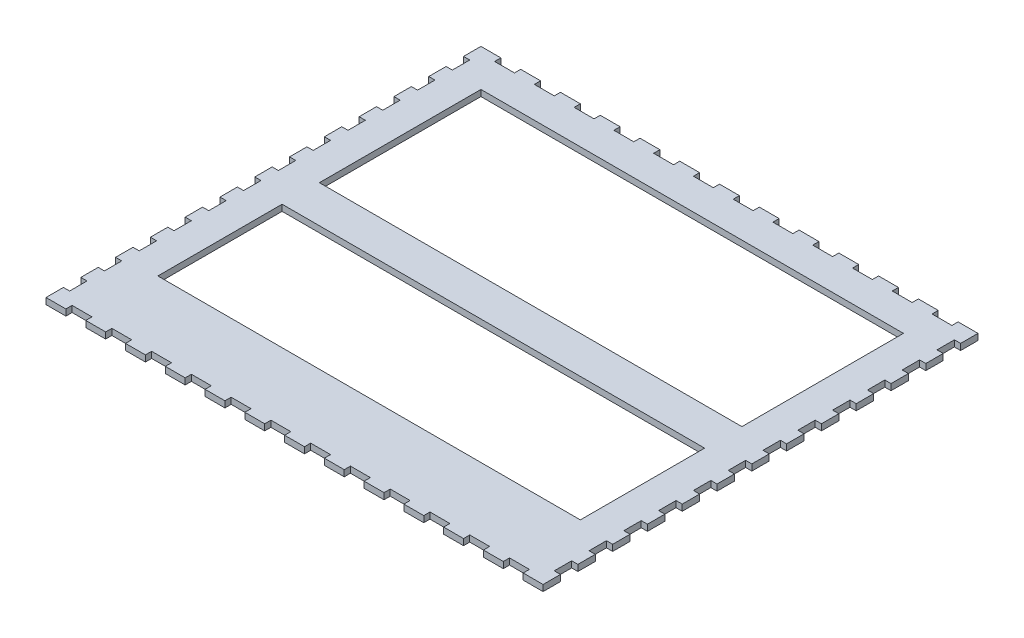
from build123d import *

# Parameters (mm, degrees)
ESQUISSE1_W                = 400
ESQUISSE1_H                = 350
BOSS_EXTRU_1_DEPTH         = 5
ESQUISSE2_W                = 16
ESQUISSE2_H                = 5
ENL_V_MAT_EXTRU_1_DEPTH    = 5
R_P_TITION_LIN_AIRE1_COUNT = 12
R_P_TITION_LIN_AIRE1_PITCH = 32
ESQUISSE3_W                = 5
ESQUISSE3_H                = 14
ENL_V_MAT_EXTRU_2_DEPTH    = 5
R_P_TITION_LIN_AIRE2_COUNT = 12
R_P_TITION_LIN_AIRE2_PITCH = 28
SYM_TRIE1_COPY_1_SKETCH_W  = 16
SYM_TRIE1_COPY_1_SKETCH_H  = 5
SYM_TRIE1_COPY_1_DEPTH     = 5
SYM_TRIE1_COPY_2_SKETCH_W  = 16
SYM_TRIE1_COPY_2_SKETCH_H  = 5
SYM_TRIE1_COPY_2_DEPTH     = 5
SYM_TRIE1_COPY_3_SKETCH_W  = 16
SYM_TRIE1_COPY_3_SKETCH_H  = 5
SYM_TRIE1_COPY_3_DEPTH     = 5
SYM_TRIE1_COPY_4_SKETCH_W  = 16
SYM_TRIE1_COPY_4_SKETCH_H  = 5
SYM_TRIE1_COPY_4_DEPTH     = 5
SYM_TRIE1_COPY_5_SKETCH_W  = 16
SYM_TRIE1_COPY_5_SKETCH_H  = 5
SYM_TRIE1_COPY_5_DEPTH     = 5
SYM_TRIE1_COPY_6_SKETCH_W  = 16
SYM_TRIE1_COPY_6_SKETCH_H  = 5
SYM_TRIE1_COPY_6_DEPTH     = 5
SYM_TRIE1_COPY_7_SKETCH_W  = 16
SYM_TRIE1_COPY_7_SKETCH_H  = 5
SYM_TRIE1_COPY_7_DEPTH     = 5
SYM_TRIE1_COPY_8_SKETCH_W  = 16
SYM_TRIE1_COPY_8_SKETCH_H  = 5
SYM_TRIE1_COPY_8_DEPTH     = 5
SYM_TRIE1_COPY_9_SKETCH_W  = 16
SYM_TRIE1_COPY_9_SKETCH_H  = 5
SYM_TRIE1_COPY_9_DEPTH     = 5
SYM_TRIE1_COPY_10_SKETCH_W = 16
SYM_TRIE1_COPY_10_SKETCH_H = 5
SYM_TRIE1_COPY_10_DEPTH    = 5
SYM_TRIE1_COPY_11_SKETCH_W = 16
SYM_TRIE1_COPY_11_SKETCH_H = 5
SYM_TRIE1_COPY_11_DEPTH    = 5
SYM_TRIE2_COPY_1_SKETCH_W  = 5
SYM_TRIE2_COPY_1_SKETCH_H  = 14
SYM_TRIE2_COPY_1_DEPTH     = 5
SYM_TRIE2_COPY_2_SKETCH_W  = 5
SYM_TRIE2_COPY_2_SKETCH_H  = 14
SYM_TRIE2_COPY_2_DEPTH     = 5
SYM_TRIE2_COPY_3_SKETCH_W  = 5
SYM_TRIE2_COPY_3_SKETCH_H  = 14
SYM_TRIE2_COPY_3_DEPTH     = 5
SYM_TRIE2_COPY_4_SKETCH_W  = 5
SYM_TRIE2_COPY_4_SKETCH_H  = 14
SYM_TRIE2_COPY_4_DEPTH     = 5
SYM_TRIE2_COPY_5_SKETCH_W  = 5
SYM_TRIE2_COPY_5_SKETCH_H  = 14
SYM_TRIE2_COPY_5_DEPTH     = 5
SYM_TRIE2_COPY_6_SKETCH_W  = 5
SYM_TRIE2_COPY_6_SKETCH_H  = 14
SYM_TRIE2_COPY_6_DEPTH     = 5
SYM_TRIE2_COPY_7_SKETCH_W  = 5
SYM_TRIE2_COPY_7_SKETCH_H  = 14
SYM_TRIE2_COPY_7_DEPTH     = 5
SYM_TRIE2_COPY_8_SKETCH_W  = 5
SYM_TRIE2_COPY_8_SKETCH_H  = 14
SYM_TRIE2_COPY_8_DEPTH     = 5
SYM_TRIE2_COPY_9_SKETCH_W  = 5
SYM_TRIE2_COPY_9_SKETCH_H  = 14
SYM_TRIE2_COPY_9_DEPTH     = 5
SYM_TRIE2_COPY_10_SKETCH_W = 5
SYM_TRIE2_COPY_10_SKETCH_H = 14
SYM_TRIE2_COPY_10_DEPTH    = 5
SYM_TRIE2_COPY_11_SKETCH_W = 5
SYM_TRIE2_COPY_11_SKETCH_H = 14
SYM_TRIE2_COPY_11_DEPTH    = 5
ESQUISSE4_W                = 340
ESQUISSE4_H                = 130
ENL_V_MAT_EXTRU_3_DEPTH    = 10
ESQUISSE5_W                = 340
ESQUISSE5_H                = 100
ENL_V_MAT_EXTRU_4_DEPTH    = 10


with BuildPart() as part:
    # Esquisse1 → Boss.-Extru.1 (new body)
    with BuildSketch(Plane(origin=(0, 0, 0), x_dir=(1, 0, 0), z_dir=(0, 1, 0))):
        with Locations((200, -175)):
            Rectangle(ESQUISSE1_W, ESQUISSE1_H)
    extrude(amount=BOSS_EXTRU_1_DEPTH)

    # Esquisse2 → Enlèv. mat.-Extru.1 (cut)
    with BuildSketch(Plane(origin=(0, 5, 0), x_dir=(1, 0, 0), z_dir=(0, 1, 0))):
        with Locations((24, -2.5)):
            Rectangle(ESQUISSE2_W, ESQUISSE2_H)
    enl_v_mat_extru_1 = extrude(amount=-ENL_V_MAT_EXTRU_1_DEPTH, mode=Mode.SUBTRACT)

    # Répétition linéaire1: Enlèv. mat.-Extru.1 ×12
    with Locations(*[(i * R_P_TITION_LIN_AIRE1_PITCH, 0, 0) for i in range(1, R_P_TITION_LIN_AIRE1_COUNT)]):
        add(enl_v_mat_extru_1, mode=Mode.SUBTRACT)

    # Esquisse3 → Enlèv. mat.-Extru.2 (cut)
    with BuildSketch(Plane(origin=(0, 5, 0), x_dir=(1, 0, 0), z_dir=(0, 1, 0))):
        with Locations((2.5, -21)):
            Rectangle(ESQUISSE3_W, ESQUISSE3_H)
    enl_v_mat_extru_2 = extrude(amount=-ENL_V_MAT_EXTRU_2_DEPTH, mode=Mode.SUBTRACT)

    # Répétition linéaire2: Enlèv. mat.-Extru.2 ×12
    with Locations(*[(0, 0, i * R_P_TITION_LIN_AIRE2_PITCH) for i in range(1, R_P_TITION_LIN_AIRE2_COUNT)]):
        add(enl_v_mat_extru_2, mode=Mode.SUBTRACT)

    # Symétrie1: Enlèv. mat.-Extru.1 across plane
    add(enl_v_mat_extru_1.mirror(Plane(origin=(0, 0, 175), x_dir=(1, 0, 0), z_dir=(0, 0, -1))), mode=Mode.SUBTRACT)

    # Symétrie1 copy 1 sketch → Symétrie1 copy 1 (cut)
    with BuildSketch(Plane(origin=(32, 5, 350), x_dir=(1, 0, 0), z_dir=(0, 1, 0))):
        with Locations((24, 2.5)):
            Rectangle(SYM_TRIE1_COPY_1_SKETCH_W, SYM_TRIE1_COPY_1_SKETCH_H)
    extrude(amount=-SYM_TRIE1_COPY_1_DEPTH, mode=Mode.SUBTRACT)

    # Symétrie1 copy 2 sketch → Symétrie1 copy 2 (cut)
    with BuildSketch(Plane(origin=(64, 5, 350), x_dir=(1, 0, 0), z_dir=(0, 1, 0))):
        with Locations((24, 2.5)):
            Rectangle(SYM_TRIE1_COPY_2_SKETCH_W, SYM_TRIE1_COPY_2_SKETCH_H)
    extrude(amount=-SYM_TRIE1_COPY_2_DEPTH, mode=Mode.SUBTRACT)

    # Symétrie1 copy 3 sketch → Symétrie1 copy 3 (cut)
    with BuildSketch(Plane(origin=(96, 5, 350), x_dir=(1, 0, 0), z_dir=(0, 1, 0))):
        with Locations((24, 2.5)):
            Rectangle(SYM_TRIE1_COPY_3_SKETCH_W, SYM_TRIE1_COPY_3_SKETCH_H)
    extrude(amount=-SYM_TRIE1_COPY_3_DEPTH, mode=Mode.SUBTRACT)

    # Symétrie1 copy 4 sketch → Symétrie1 copy 4 (cut)
    with BuildSketch(Plane(origin=(128, 5, 350), x_dir=(1, 0, 0), z_dir=(0, 1, 0))):
        with Locations((24, 2.5)):
            Rectangle(SYM_TRIE1_COPY_4_SKETCH_W, SYM_TRIE1_COPY_4_SKETCH_H)
    extrude(amount=-SYM_TRIE1_COPY_4_DEPTH, mode=Mode.SUBTRACT)

    # Symétrie1 copy 5 sketch → Symétrie1 copy 5 (cut)
    with BuildSketch(Plane(origin=(160, 5, 350), x_dir=(1, 0, 0), z_dir=(0, 1, 0))):
        with Locations((24, 2.5)):
            Rectangle(SYM_TRIE1_COPY_5_SKETCH_W, SYM_TRIE1_COPY_5_SKETCH_H)
    extrude(amount=-SYM_TRIE1_COPY_5_DEPTH, mode=Mode.SUBTRACT)

    # Symétrie1 copy 6 sketch → Symétrie1 copy 6 (cut)
    with BuildSketch(Plane(origin=(192, 5, 350), x_dir=(1, 0, 0), z_dir=(0, 1, 0))):
        with Locations((24, 2.5)):
            Rectangle(SYM_TRIE1_COPY_6_SKETCH_W, SYM_TRIE1_COPY_6_SKETCH_H)
    extrude(amount=-SYM_TRIE1_COPY_6_DEPTH, mode=Mode.SUBTRACT)

    # Symétrie1 copy 7 sketch → Symétrie1 copy 7 (cut)
    with BuildSketch(Plane(origin=(224, 5, 350), x_dir=(1, 0, 0), z_dir=(0, 1, 0))):
        with Locations((24, 2.5)):
            Rectangle(SYM_TRIE1_COPY_7_SKETCH_W, SYM_TRIE1_COPY_7_SKETCH_H)
    extrude(amount=-SYM_TRIE1_COPY_7_DEPTH, mode=Mode.SUBTRACT)

    # Symétrie1 copy 8 sketch → Symétrie1 copy 8 (cut)
    with BuildSketch(Plane(origin=(256, 5, 350), x_dir=(1, 0, 0), z_dir=(0, 1, 0))):
        with Locations((24, 2.5)):
            Rectangle(SYM_TRIE1_COPY_8_SKETCH_W, SYM_TRIE1_COPY_8_SKETCH_H)
    extrude(amount=-SYM_TRIE1_COPY_8_DEPTH, mode=Mode.SUBTRACT)

    # Symétrie1 copy 9 sketch → Symétrie1 copy 9 (cut)
    with BuildSketch(Plane(origin=(288, 5, 350), x_dir=(1, 0, 0), z_dir=(0, 1, 0))):
        with Locations((24, 2.5)):
            Rectangle(SYM_TRIE1_COPY_9_SKETCH_W, SYM_TRIE1_COPY_9_SKETCH_H)
    extrude(amount=-SYM_TRIE1_COPY_9_DEPTH, mode=Mode.SUBTRACT)

    # Symétrie1 copy 10 sketch → Symétrie1 copy 10 (cut)
    with BuildSketch(Plane(origin=(320, 5, 350), x_dir=(1, 0, 0), z_dir=(0, 1, 0))):
        with Locations((24, 2.5)):
            Rectangle(SYM_TRIE1_COPY_10_SKETCH_W, SYM_TRIE1_COPY_10_SKETCH_H)
    extrude(amount=-SYM_TRIE1_COPY_10_DEPTH, mode=Mode.SUBTRACT)

    # Symétrie1 copy 11 sketch → Symétrie1 copy 11 (cut)
    with BuildSketch(Plane(origin=(352, 5, 350), x_dir=(1, 0, 0), z_dir=(0, 1, 0))):
        with Locations((24, 2.5)):
            Rectangle(SYM_TRIE1_COPY_11_SKETCH_W, SYM_TRIE1_COPY_11_SKETCH_H)
    extrude(amount=-SYM_TRIE1_COPY_11_DEPTH, mode=Mode.SUBTRACT)

    # Symétrie2: Enlèv. mat.-Extru.2 across plane
    add(enl_v_mat_extru_2.mirror(Plane(origin=(200, 0, 0), x_dir=(0, 0, 1), z_dir=(1, 0, 0))), mode=Mode.SUBTRACT)

    # Symétrie2 copy 1 sketch → Symétrie2 copy 1 (cut)
    with BuildSketch(Plane(origin=(400, 5, 28), x_dir=(-1, 0, 0), z_dir=(0, 1, 0))):
        with Locations((2.5, 21)):
            Rectangle(SYM_TRIE2_COPY_1_SKETCH_W, SYM_TRIE2_COPY_1_SKETCH_H)
    extrude(amount=-SYM_TRIE2_COPY_1_DEPTH, mode=Mode.SUBTRACT)

    # Symétrie2 copy 2 sketch → Symétrie2 copy 2 (cut)
    with BuildSketch(Plane(origin=(400, 5, 56), x_dir=(-1, 0, 0), z_dir=(0, 1, 0))):
        with Locations((2.5, 21)):
            Rectangle(SYM_TRIE2_COPY_2_SKETCH_W, SYM_TRIE2_COPY_2_SKETCH_H)
    extrude(amount=-SYM_TRIE2_COPY_2_DEPTH, mode=Mode.SUBTRACT)

    # Symétrie2 copy 3 sketch → Symétrie2 copy 3 (cut)
    with BuildSketch(Plane(origin=(400, 5, 84), x_dir=(-1, 0, 0), z_dir=(0, 1, 0))):
        with Locations((2.5, 21)):
            Rectangle(SYM_TRIE2_COPY_3_SKETCH_W, SYM_TRIE2_COPY_3_SKETCH_H)
    extrude(amount=-SYM_TRIE2_COPY_3_DEPTH, mode=Mode.SUBTRACT)

    # Symétrie2 copy 4 sketch → Symétrie2 copy 4 (cut)
    with BuildSketch(Plane(origin=(400, 5, 112), x_dir=(-1, 0, 0), z_dir=(0, 1, 0))):
        with Locations((2.5, 21)):
            Rectangle(SYM_TRIE2_COPY_4_SKETCH_W, SYM_TRIE2_COPY_4_SKETCH_H)
    extrude(amount=-SYM_TRIE2_COPY_4_DEPTH, mode=Mode.SUBTRACT)

    # Symétrie2 copy 5 sketch → Symétrie2 copy 5 (cut)
    with BuildSketch(Plane(origin=(400, 5, 140), x_dir=(-1, 0, 0), z_dir=(0, 1, 0))):
        with Locations((2.5, 21)):
            Rectangle(SYM_TRIE2_COPY_5_SKETCH_W, SYM_TRIE2_COPY_5_SKETCH_H)
    extrude(amount=-SYM_TRIE2_COPY_5_DEPTH, mode=Mode.SUBTRACT)

    # Symétrie2 copy 6 sketch → Symétrie2 copy 6 (cut)
    with BuildSketch(Plane(origin=(400, 5, 168), x_dir=(-1, 0, 0), z_dir=(0, 1, 0))):
        with Locations((2.5, 21)):
            Rectangle(SYM_TRIE2_COPY_6_SKETCH_W, SYM_TRIE2_COPY_6_SKETCH_H)
    extrude(amount=-SYM_TRIE2_COPY_6_DEPTH, mode=Mode.SUBTRACT)

    # Symétrie2 copy 7 sketch → Symétrie2 copy 7 (cut)
    with BuildSketch(Plane(origin=(400, 5, 196), x_dir=(-1, 0, 0), z_dir=(0, 1, 0))):
        with Locations((2.5, 21)):
            Rectangle(SYM_TRIE2_COPY_7_SKETCH_W, SYM_TRIE2_COPY_7_SKETCH_H)
    extrude(amount=-SYM_TRIE2_COPY_7_DEPTH, mode=Mode.SUBTRACT)

    # Symétrie2 copy 8 sketch → Symétrie2 copy 8 (cut)
    with BuildSketch(Plane(origin=(400, 5, 224), x_dir=(-1, 0, 0), z_dir=(0, 1, 0))):
        with Locations((2.5, 21)):
            Rectangle(SYM_TRIE2_COPY_8_SKETCH_W, SYM_TRIE2_COPY_8_SKETCH_H)
    extrude(amount=-SYM_TRIE2_COPY_8_DEPTH, mode=Mode.SUBTRACT)

    # Symétrie2 copy 9 sketch → Symétrie2 copy 9 (cut)
    with BuildSketch(Plane(origin=(400, 5, 252), x_dir=(-1, 0, 0), z_dir=(0, 1, 0))):
        with Locations((2.5, 21)):
            Rectangle(SYM_TRIE2_COPY_9_SKETCH_W, SYM_TRIE2_COPY_9_SKETCH_H)
    extrude(amount=-SYM_TRIE2_COPY_9_DEPTH, mode=Mode.SUBTRACT)

    # Symétrie2 copy 10 sketch → Symétrie2 copy 10 (cut)
    with BuildSketch(Plane(origin=(400, 5, 280), x_dir=(-1, 0, 0), z_dir=(0, 1, 0))):
        with Locations((2.5, 21)):
            Rectangle(SYM_TRIE2_COPY_10_SKETCH_W, SYM_TRIE2_COPY_10_SKETCH_H)
    extrude(amount=-SYM_TRIE2_COPY_10_DEPTH, mode=Mode.SUBTRACT)

    # Symétrie2 copy 11 sketch → Symétrie2 copy 11 (cut)
    with BuildSketch(Plane(origin=(400, 5, 308), x_dir=(-1, 0, 0), z_dir=(0, 1, 0))):
        with Locations((2.5, 21)):
            Rectangle(SYM_TRIE2_COPY_11_SKETCH_W, SYM_TRIE2_COPY_11_SKETCH_H)
    extrude(amount=-SYM_TRIE2_COPY_11_DEPTH, mode=Mode.SUBTRACT)

    # Esquisse4 → Enlèv. mat.-Extru.3 (cut)
    with BuildSketch(Plane(origin=(0, 5, 0), x_dir=(1, 0, 0), z_dir=(0, 1, 0))):
        with Locations((200, -95)):
            Rectangle(ESQUISSE4_W, ESQUISSE4_H)
    extrude(amount=-ENL_V_MAT_EXTRU_3_DEPTH, mode=Mode.SUBTRACT)

    # Esquisse5 → Enlèv. mat.-Extru.4 (cut)
    with BuildSketch(Plane(origin=(0, 5, 0), x_dir=(1, 0, 0), z_dir=(0, 1, 0))):
        with Locations((200, -240)):
            Rectangle(ESQUISSE5_W, ESQUISSE5_H)
    extrude(amount=-ENL_V_MAT_EXTRU_4_DEPTH, mode=Mode.SUBTRACT)


solid = part.part
